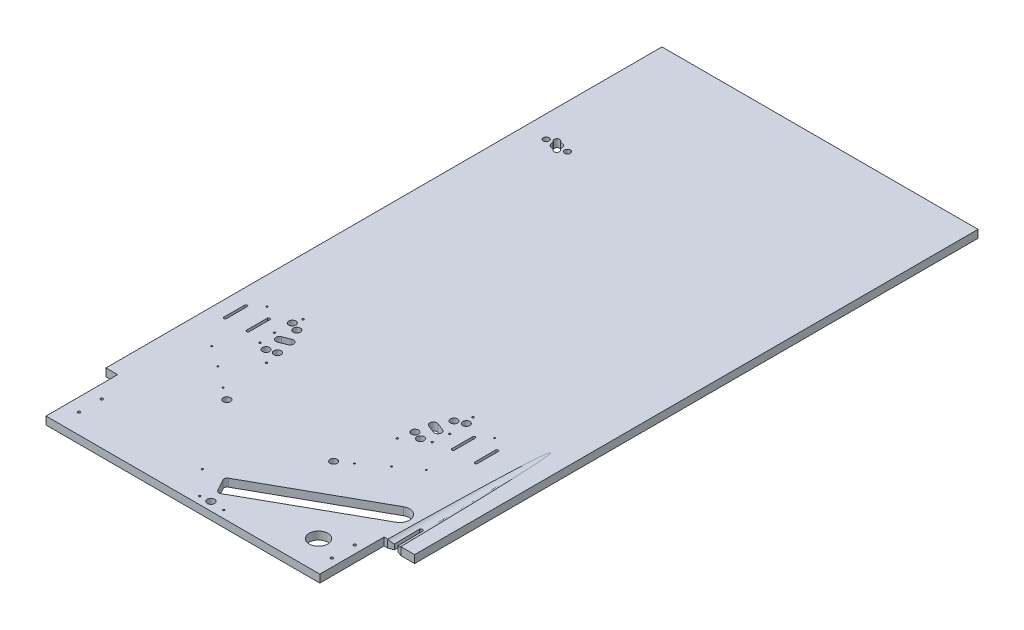
from build123d import *

# Parameters (mm, degrees)
SKETCH1_R           = 5.824269922
SKETCH1_R_2         = 15.183436718
SKETCH1_R_3         = 2.097724336
SKETCH1_R_4         = 1.501171646
SKETCH1_R_5         = 6.046381911
SKETCH1_R_6         = 1.233955492
SKETCH1_R_7         = 4.738389089
SKETCH1_R_8         = 1.524
BOSS_EXTRUDE1_DEPTH = 12.7
SKETCH3_R           = 14.2875


with BuildPart() as part:
    # Sketch1 → Boss-Extrude1 (new body)
    with BuildSketch(Plane(origin=(0, 0, 0), x_dir=(1, 0, 0), z_dir=(0, 1, 0))):
        with BuildLine():
            Line((181.053619211, 279.591938546), (200.093166842, 279.591938546))
            Line((200.093166842, 279.591938546), (200.093166842, 162.94458344))
            Line((200.093166842, 162.94458344), (645.714984179, 162.94458344))
            Line((645.714984179, 162.94458344), (645.714984179, 267.541591944))
            Line((645.714984179, 267.541591944), (651.459778015, 267.541591944))
            Line((651.459778015, 267.541591944), (659.592709072, 270.588129637))
            Line((659.592709072, 270.588129637), (659.592709072, 310.92735289))
            ThreePointArc((659.592709072, 310.92735289), (662.356769374, 313.691413192), (665.120829676, 310.92735289))
            Line((665.120829676, 310.92735289), (665.120829676, 270.588129637))
            Line((665.120829676, 270.588129637), (673.253760733, 267.541591944))
            Line((673.253760733, 267.541591944), (695.362412179, 267.541591944))
            Line((695.362412179, 267.541591944), (695.362412179, 1184.427811096))
            Line((695.362412179, 1184.427811096), (181.053619211, 1184.427811096))
            Line((181.053619211, 1184.427811096), (181.053619211, 279.591938546))
        make_face()
        with Locations(Location((324.163687625, 333.156445716, 0), (0, 0, 270))):  # turned: the seam where the file's is
            Circle(SKETCH1_R, mode=Mode.SUBTRACT)
        with Locations(Location((498.003337343, 333.156445716, 0), (0, 0, 270))):  # turned: the seam where the file's is
            Circle(SKETCH1_R, mode=Mode.SUBTRACT)
        with Locations(Location((285.454913552, 435.726712451, 0), (0, 0, 270))):  # turned: the seam where the file's is
            Circle(SKETCH1_R, mode=Mode.SUBTRACT)
        with Locations(Location((269.478274819, 494.373532098, 0), (0, 0, 270))):  # turned: the seam where the file's is
            Circle(SKETCH1_R, mode=Mode.SUBTRACT)
        with Locations(Location((283.113483006, 488.0772742, 0), (0, 0, 270))):  # turned: the seam where the file's is
            Circle(SKETCH1_R, mode=Mode.SUBTRACT)
        with Locations(Location((299.283235774, 440.456463852, 0), (0, 0, 270))):  # turned: the seam where the file's is
            Circle(SKETCH1_R, mode=Mode.SUBTRACT)
        with Locations(Location((536.712111416, 435.726712451, 0), (0, 0, 270))):  # turned: the seam where the file's is
            Circle(SKETCH1_R, mode=Mode.SUBTRACT)
        with Locations(Location((552.688750149, 494.373532098, 0), (0, 0, 270))):  # turned: the seam where the file's is
            Circle(SKETCH1_R, mode=Mode.SUBTRACT)
        with Locations(Location((539.053541962, 488.0772742, 0), (0, 0, 270))):  # turned: the seam where the file's is
            Circle(SKETCH1_R, mode=Mode.SUBTRACT)
        with Locations(Location((522.883789195, 440.456463852, 0), (0, 0, 270))):  # turned: the seam where the file's is
            Circle(SKETCH1_R, mode=Mode.SUBTRACT)
        with Locations(Location((594.651015644, 211.880261627, 0), (0, 0, 270))):  # turned: the seam where the file's is
            Circle(SKETCH1_R_2, mode=Mode.SUBTRACT)
        with Locations(Location((221.612450161, 232.383888713, 0), (0, 0, 270))):  # turned: the seam where the file's is
            Circle(SKETCH1_R_3, mode=Mode.SUBTRACT)
        with Locations(Location((221.612450161, 195.241828402, 0), (0, 0, 270))):  # turned: the seam where the file's is
            Circle(SKETCH1_R_3, mode=Mode.SUBTRACT)
        with Locations(Location((633.069124813, 232.383888713, 0), (0, 0, 270))):  # turned: the seam where the file's is
            Circle(SKETCH1_R_3, mode=Mode.SUBTRACT)
        with Locations(Location((633.069124813, 195.241828402, 0), (0, 0, 270))):  # turned: the seam where the file's is
            Circle(SKETCH1_R_3, mode=Mode.SUBTRACT)
        with Locations(Location((402.196528277, 215.362632519, 0), (0, 0, 270))):  # turned: the seam where the file's is
            Circle(SKETCH1_R_4, mode=Mode.SUBTRACT)
        with Locations(Location((438.228028644, 175.135683479, 0), (0, 0, 270))):  # turned: the seam where the file's is
            Circle(SKETCH1_R_4, mode=Mode.SUBTRACT)
        with Locations(Location((477.221022192, 175.135683479, 0), (0, 0, 270))):  # turned: the seam where the file's is
            Circle(SKETCH1_R_4, mode=Mode.SUBTRACT)
        with Locations(Location((454.639636688, 176.863221168, 0), (0, 0, 270))):  # turned: the seam where the file's is
            Circle(SKETCH1_R_5, mode=Mode.SUBTRACT)
        with Locations(Location((225.832143337, 496.894899007, 0), (0, 0, 270))):  # turned: the seam where the file's is
            Circle(SKETCH1_R_6, mode=Mode.SUBTRACT)
        with Locations(Location((236.567556118, 396.296677519, 0), (0, 0, 270))):  # turned: the seam where the file's is
            Circle(SKETCH1_R_6, mode=Mode.SUBTRACT)
        with Locations(Location((269.884354403, 372.851523171, 0), (0, 0, 270))):  # turned: the seam where the file's is
            Circle(SKETCH1_R_6, mode=Mode.SUBTRACT)
        with Locations(Location((304.280863743, 346.938457838, 0), (0, 0, 270))):  # turned: the seam where the file's is
            Circle(SKETCH1_R_6, mode=Mode.SUBTRACT)
        with Locations(Location((596.334881631, 496.894899007, 0), (0, 0, 270))):  # turned: the seam where the file's is
            Circle(SKETCH1_R_6, mode=Mode.SUBTRACT)
        with Locations(Location((585.59946885, 396.296677519, 0), (0, 0, 270))):  # turned: the seam where the file's is
            Circle(SKETCH1_R_6, mode=Mode.SUBTRACT)
        with Locations(Location((552.282670565, 372.851523171, 0), (0, 0, 270))):  # turned: the seam where the file's is
            Circle(SKETCH1_R_6, mode=Mode.SUBTRACT)
        with Locations(Location((517.886161225, 346.938457838, 0), (0, 0, 270))):  # turned: the seam where the file's is
            Circle(SKETCH1_R_6, mode=Mode.SUBTRACT)
        with Locations(Location((217.200519411, 959.83603663, 0), (0, 0, 270))):  # turned: the seam where the file's is
            Circle(SKETCH1_R_7, mode=Mode.SUBTRACT)
        with Locations(Location((251.849989627, 959.83603663, 0), (0, 0, 270))):  # turned: the seam where the file's is
            Circle(SKETCH1_R_7, mode=Mode.SUBTRACT)
        with Locations(Location((272.894732067, 508.643077531, 0), (0, 0, 270))):  # turned: the seam where the file's is
            Circle(SKETCH1_R_8, mode=Mode.SUBTRACT)
        with Locations(Location((268.450589155, 466.396381192, 0), (0, 0, 270))):  # turned: the seam where the file's is
            Circle(SKETCH1_R_8, mode=Mode.SUBTRACT)
        with Locations(Location((271.126563031, 440.408557976, 0), (0, 0, 270))):  # turned: the seam where the file's is
            Circle(SKETCH1_R_8, mode=Mode.SUBTRACT)
        with Locations(Location((304.473314405, 417.292260573, 0), (0, 0, 270))):  # turned: the seam where the file's is
            Circle(SKETCH1_R_8, mode=Mode.SUBTRACT)
        with Locations(Location((549.272292901, 508.643077531, 0), (0, 0, 270))):  # turned: the seam where the file's is
            Circle(SKETCH1_R_8, mode=Mode.SUBTRACT)
        with Locations(Location((553.716435813, 466.396381192, 0), (0, 0, 270))):  # turned: the seam where the file's is
            Circle(SKETCH1_R_8, mode=Mode.SUBTRACT)
        with Locations(Location((551.040461937, 440.408557976, 0), (0, 0, 270))):  # turned: the seam where the file's is
            Circle(SKETCH1_R_8, mode=Mode.SUBTRACT)
        with Locations(Location((517.693710564, 417.292260573, 0), (0, 0, 270))):  # turned: the seam where the file's is
            Circle(SKETCH1_R_8, mode=Mode.SUBTRACT)
        with BuildLine():
            Line((280.043534807, 466.342038413), (292.284373288, 471.080427502))
            ThreePointArc((292.284373288, 471.080427502), (299.818428707, 467.751426271), (296.489427475, 460.217370852))
            Line((296.489427475, 460.217370852), (284.248588994, 455.478981762))
            ThreePointArc((284.248588994, 455.478981762), (276.714533575, 458.807982994), (280.043534807, 466.342038413))
        make_face(mode=Mode.SUBTRACT)
        with BuildLine():
            Line((542.123490162, 466.342038413), (529.882651681, 471.080427502))
            ThreePointArc((529.882651681, 471.080427502), (522.348596262, 467.751426271), (525.677597493, 460.217370852))
            Line((525.677597493, 460.217370852), (537.918435974, 455.478981762))
            ThreePointArc((537.918435974, 455.478981762), (545.452491393, 458.807982994), (542.123490162, 466.342038413))
        make_face(mode=Mode.SUBTRACT)
        with BuildLine():
            Line((209.707710439, 480.9937085), (209.707710439, 447.193199663))
            ThreePointArc((209.707710439, 447.193199663), (207.575435349, 445.060924572), (205.443160259, 447.193199663))
            Line((205.443160259, 447.193199663), (205.443160259, 480.9937085))
            ThreePointArc((205.443160259, 480.9937085), (207.575435349, 483.12598359), (209.707710439, 480.9937085))
        make_face(mode=Mode.SUBTRACT)
        with BuildLine():
            Line((242.244648853, 480.9937085), (242.244648853, 447.193199663))
            ThreePointArc((242.244648853, 447.193199663), (244.376923944, 445.060924572), (246.509199034, 447.193199663))
            Line((246.509199034, 447.193199663), (246.509199034, 480.9937085))
            ThreePointArc((246.509199034, 480.9937085), (244.376923944, 483.12598359), (242.244648853, 480.9937085))
        make_face(mode=Mode.SUBTRACT)
        with BuildLine():
            Line((576.352211687, 480.9937085), (576.352211687, 447.193199663))
            ThreePointArc((576.352211687, 447.193199663), (578.484486777, 445.060924572), (580.616761867, 447.193199663))
            Line((580.616761867, 447.193199663), (580.616761867, 480.9937085))
            ThreePointArc((580.616761867, 480.9937085), (578.484486777, 483.12598359), (576.352211687, 480.9937085))
        make_face(mode=Mode.SUBTRACT)
        with BuildLine():
            Line((613.864458645, 480.9937085), (613.864458645, 447.193199663))
            ThreePointArc((613.864458645, 447.193199663), (615.996733735, 445.060924572), (618.129008825, 447.193199663))
            Line((618.129008825, 447.193199663), (618.129008825, 480.9937085))
            ThreePointArc((618.129008825, 480.9937085), (615.996733735, 483.12598359), (613.864458645, 480.9937085))
        make_face(mode=Mode.SUBTRACT)
        with BuildLine():
            Line((640.619770917, 319.710384153), (640.545012441, 319.844114807))
            ThreePointArc((640.545012441, 319.844114807), (630.971841378, 327.402872478), (618.857738395, 325.978467108))
            Line((618.857738395, 325.978467108), (436.133708882, 223.831579783))
            ThreePointArc((436.133708882, 223.831579783), (433.695399956, 220.743460085), (434.154885559, 216.835684929))
            Line((434.154885559, 216.835684929), (444.765494249, 197.855046105))
            ThreePointArc((444.765494249, 197.855046105), (447.853613947, 195.416737179), (451.761389102, 195.876222782))
            Line((451.761389102, 195.876222782), (634.485418615, 298.023110107))
            ThreePointArc((634.485418615, 298.023110107), (642.044176286, 307.59628117), (640.619770917, 319.710384153))
        make_face(mode=Mode.SUBTRACT)
        with BuildLine():
            Line((235.713447154, 952.32831259), (237.858461253, 950.094878062))
            ThreePointArc((237.858461253, 950.094878062), (243.9998787, 949.970855421), (244.123901341, 956.112272868))
            Line((244.123901341, 956.112272868), (241.978887242, 958.345707396))
            ThreePointArc((241.978887242, 958.345707396), (240.007514596, 965.101257084), (233.337061884, 967.343760669))
            Line((233.337061884, 967.343760669), (231.192047785, 969.577195197))
            ThreePointArc((231.192047785, 969.577195197), (225.050630338, 969.701217838), (224.926607697, 963.559800391))
            Line((224.926607697, 963.559800391), (227.071621796, 961.326365863))
            ThreePointArc((227.071621796, 961.326365863), (229.042994442, 954.570816175), (235.713447154, 952.32831259))
        make_face(mode=Mode.SUBTRACT)
    extrude(amount=BOSS_EXTRUDE1_DEPTH)

    # Cut-Sweep1: sweep along a path in Sketch2
    with BuildLine(Plane(origin=(662.356769374, 0, 0), x_dir=(0, 0, -1), z_dir=(1, 0, 0))) as cut_sweep1_path:
        Line((267.541591944, 12.7), (521.541591944, 17.4625))
    # Sketch3 → Cut-Sweep1 (sweep, cut)
    with BuildSketch(Plane.XY.offset(-267.541591944)):
        with Locations((662.356769374, 22.225)):
            Circle(SKETCH3_R)
    sweep(path=cut_sweep1_path.line, mode=Mode.SUBTRACT)


solid = part.part
